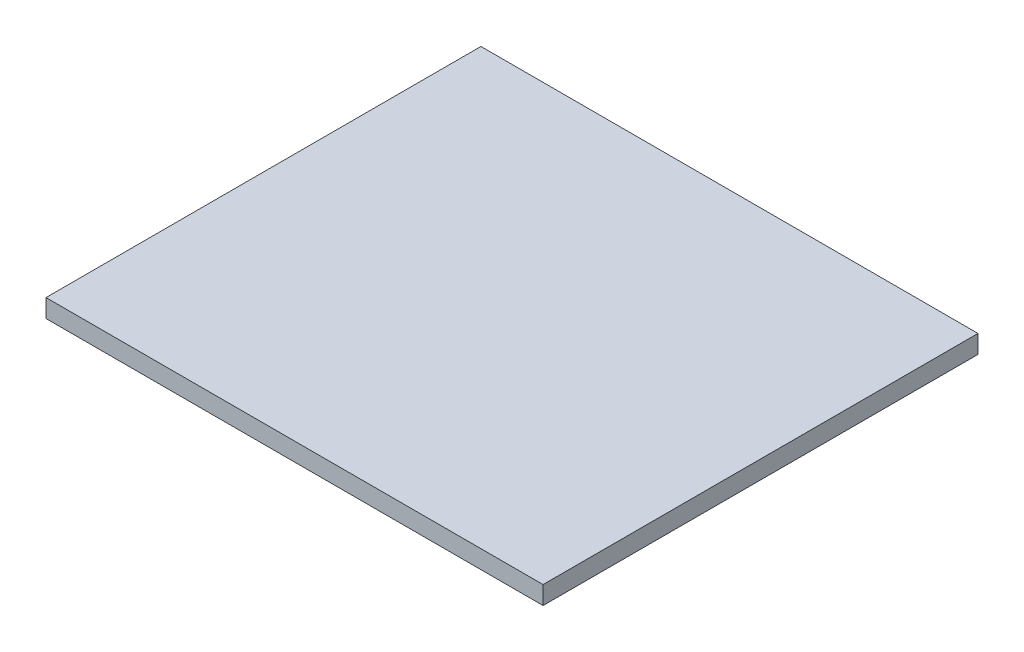
from build123d import *

# Parameters (mm, degrees)
SKETCH1_W      = 8.2
SKETCH1_H      = 7.175
EXTRUDE1_DEPTH = 0.3


with BuildPart() as part:
    # Sketch1 → Extrude1 (new body)
    with BuildSketch(Plane(origin=(0, 0, 0), x_dir=(1, 0, 0), z_dir=(0, 1, 0))):
        Rectangle(SKETCH1_W, SKETCH1_H)
    extrude(amount=EXTRUDE1_DEPTH)


solid = part.part
